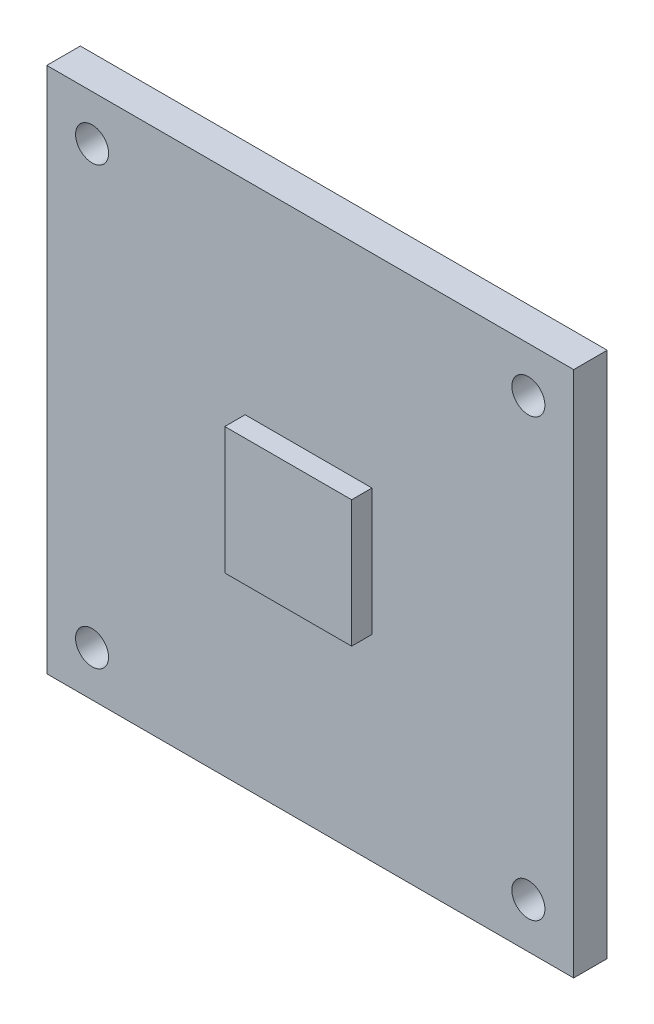
from build123d import *

# Parameters (mm, degrees)
SCHIZZO2_W                   = 39.87805
SCHIZZO2_H                   = 39.87805
ESTRUSIONE_ESTRUSIONE1_DEPTH = 2.54
FORO_FILETTATO_M3X0_5_1_D    = 2.5
SCHIZZO5_W                   = 9.6
SCHIZZO5_H                   = 9.6
ESTRUSIONE_ESTRUSIONE2_DEPTH = 1.54


with BuildPart() as part:
    # Schizzo2 → Estrusione-Estrusione1 (new body)
    with BuildSketch(Plane.XY):
        with Locations((16.509975, 16.509975)):
            Rectangle(SCHIZZO2_W, SCHIZZO2_H)
    extrude(amount=-ESTRUSIONE_ESTRUSIONE1_DEPTH)

    # Foro filettato M3x0.5-1 (through all)
    with Locations(Plane.XY):
        with Locations((0, 33.02), (33.02, 33.02), (33.02, 0), (0, 0)):
            Hole(FORO_FILETTATO_M3X0_5_1_D / 2)

    # Schizzo5 → Estrusione-Estrusione2 (add)
    with BuildSketch(Plane.XY):
        with Locations((16.383, 16.256)):
            Rectangle(SCHIZZO5_W, SCHIZZO5_H)
    extrude(amount=ESTRUSIONE_ESTRUSIONE2_DEPTH)


solid = part.part
